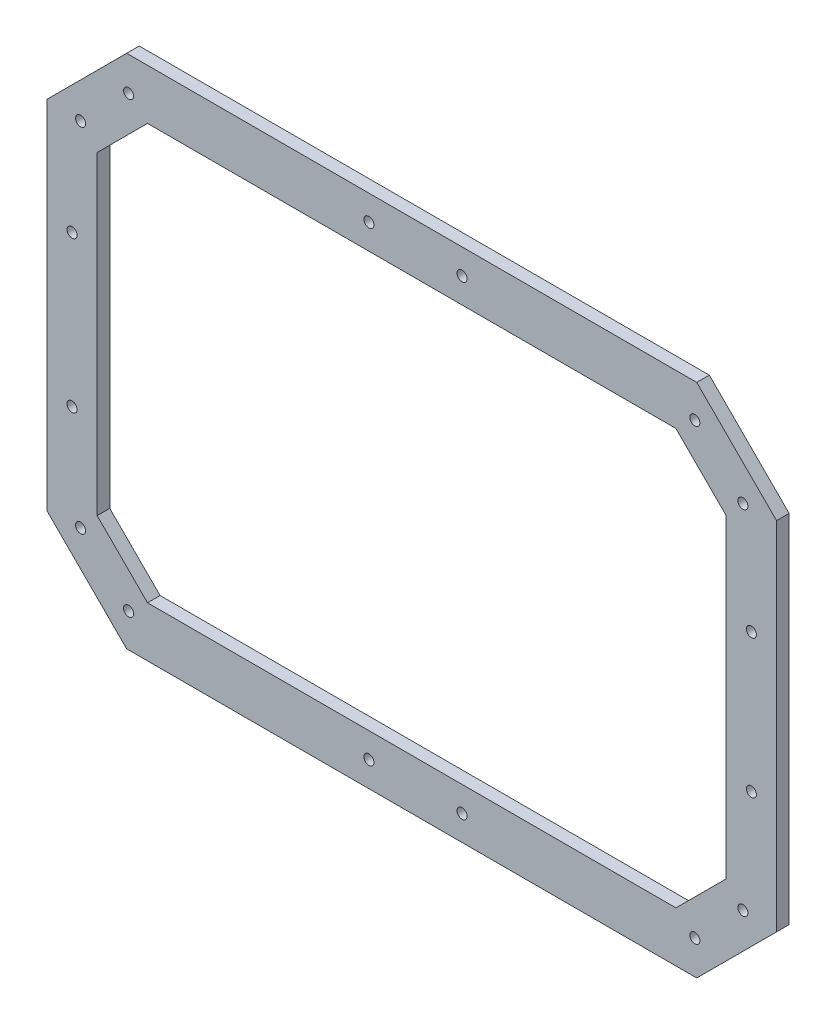
from build123d import *

# Parameters (mm, degrees)
SKETCH1_W           = 20
SKETCH1_H           = 80
SKETCH1_R           = 2
SKETCH1_W_2         = 27
SKETCH1_H_2         = 20
SKETCH1_W_3         = 30
SKETCH1_H_3         = 70
SKETCH1_W_4         = 57
BOSS_EXTRUDE1_DEPTH = 5


with BuildPart() as part:
    # Sketch1 → Boss-Extrude1 (new body)
    with BuildSketch(Plane.XY):
        Polygon((-113.154404335, -55.241611667), (-109.012268711, -59.383747291), (-109.012268711, -36.883747291), (-129.012268711, -36.883747291), (-129.012268711, -67.668018539), (-127.296539959, -69.383747291), align=None)
        with Locations((-119.012268711, 3.116252709)):
            Rectangle(SKETCH1_W, SKETCH1_H)
        with Locations((-119.012268711, -26.883747291)):
            Circle(SKETCH1_R, mode=Mode.SUBTRACT)
        with Locations((-119.012268711, 33.116252709)):
            Circle(SKETCH1_R, mode=Mode.SUBTRACT)
        Polygon((-113.154404335, -83.525882915), (-99.012268711, -69.383747291), (-109.012268711, -59.383747291), (-113.154404335, -55.241611667), (-127.296539959, -69.383747291), align=None)
        with Locations((-115.629278069, -66.908873557)):
            Circle(SKETCH1_R, mode=Mode.SUBTRACT)
        Polygon((-84.870133088, -83.525882915), (-89.012268711, -79.383747291), (-99.012268711, -69.383747291), (-113.154404335, -83.525882915), (-99.012268711, -97.668018539), align=None)
        with Locations((-96.537394977, -86.000756649)):
            Circle(SKETCH1_R, mode=Mode.SUBTRACT)
        Polygon((-11.012268711, -79.383747291), (-89.012268711, -79.383747291), (-84.870133088, -83.525882915), (-99.012268711, -97.668018539), (-97.296539959, -99.383747291), (-11.012268711, -99.383747291), align=None)
        with Locations((2.487731289, -89.383747291)):
            Rectangle(SKETCH1_W_2, SKETCH1_H_2)
        with Locations((-1.012268711, -89.383747291)):
            Circle(SKETCH1_R, mode=Mode.SUBTRACT)
        with Locations((30.987731289, -89.383747291)):
            Rectangle(SKETCH1_W_3, SKETCH1_H_2)
        with Locations((35.987731289, -89.383747291)):
            Circle(SKETCH1_R, mode=Mode.SUBTRACT)
        Polygon((116.845595665, -83.525882915), (120.987731289, -79.383747291), (45.987731289, -79.383747291), (45.987731289, -99.383747291), (129.272002536, -99.383747291), (130.987731289, -97.668018539), align=None)
        Polygon((130.987731289, -69.383747291), (120.987731289, -79.383747291), (116.845595665, -83.525882915), (130.987731289, -97.668018539), (145.129866912, -83.525882915), align=None)
        with Locations((128.512857554, -86.000756649)):
            Circle(SKETCH1_R, mode=Mode.SUBTRACT)
        Polygon((140.987731289, -59.383747291), (130.987731289, -69.383747291), (145.129866912, -83.525882915), (159.272002536, -69.383747291), (145.129866912, -55.241611667), align=None)
        with Locations((147.604740646, -66.908873557)):
            Circle(SKETCH1_R, mode=Mode.SUBTRACT)
        Polygon((140.987731289, -31.883747291), (140.987731289, -59.383747291), (145.129866912, -55.241611667), (159.272002536, -69.383747291), (160.987731289, -67.668018539), (160.987731289, -31.883747291), align=None)
        with Locations((150.987731289, 3.116252709)):
            Rectangle(SKETCH1_W, SKETCH1_H_3)
        with Locations((150.987731289, -24.383747291)):
            Circle(SKETCH1_R, mode=Mode.SUBTRACT)
        with Locations((150.987731289, 30.616252709)):
            Circle(SKETCH1_R, mode=Mode.SUBTRACT)
        Polygon((145.129866912, 61.474117085), (140.987731289, 65.616252709), (140.987731289, 38.116252709), (160.987731289, 38.116252709), (160.987731289, 73.900523956), (159.272002536, 75.616252709), align=None)
        Polygon((145.129866912, 89.758388333), (130.987731289, 75.616252709), (140.987731289, 65.616252709), (145.129866912, 61.474117085), (159.272002536, 75.616252709), align=None)
        with Locations((147.604740646, 73.141378975)):
            Circle(SKETCH1_R, mode=Mode.SUBTRACT)
        Polygon((116.845595665, 89.758388333), (120.987731289, 85.616252709), (130.987731289, 75.616252709), (145.129866912, 89.758388333), (130.987731289, 103.900523956), align=None)
        with Locations((128.512857554, 92.233262067)):
            Circle(SKETCH1_R, mode=Mode.SUBTRACT)
        Polygon((45.987731289, 105.616252709), (45.987731289, 85.616252709), (120.987731289, 85.616252709), (116.845595665, 89.758388333), (130.987731289, 103.900523956), (129.272002536, 105.616252709), align=None)
        with Locations((17.487731289, 95.616252709)):
            Rectangle(SKETCH1_W_4, SKETCH1_H_2)
        with Locations((-1.012268711, 95.616252709)):
            Circle(SKETCH1_R, mode=Mode.SUBTRACT)
        with Locations((35.987731289, 95.616252709)):
            Circle(SKETCH1_R, mode=Mode.SUBTRACT)
        Polygon((-84.870133088, 89.758388333), (-89.012268711, 85.616252709), (-11.012268711, 85.616252709), (-11.012268711, 105.616252709), (-97.296539959, 105.616252709), (-99.012268711, 103.900523956), align=None)
        Polygon((-99.012268711, 75.616252709), (-89.012268711, 85.616252709), (-84.870133088, 89.758388333), (-99.012268711, 103.900523956), (-113.154404335, 89.758388333), align=None)
        with Locations((-96.537394977, 92.233262067)):
            Circle(SKETCH1_R, mode=Mode.SUBTRACT)
        Polygon((-109.012268711, 65.616252709), (-99.012268711, 75.616252709), (-113.154404335, 89.758388333), (-127.296539959, 75.616252709), (-113.154404335, 61.474117085), align=None)
        with Locations((-115.629278069, 73.141378975)):
            Circle(SKETCH1_R, mode=Mode.SUBTRACT)
        Polygon((-109.012268711, 43.116252709), (-109.012268711, 65.616252709), (-113.154404335, 61.474117085), (-127.296539959, 75.616252709), (-129.012268711, 73.900523956), (-129.012268711, 43.116252709), align=None)
    extrude(amount=BOSS_EXTRUDE1_DEPTH)


solid = part.part
